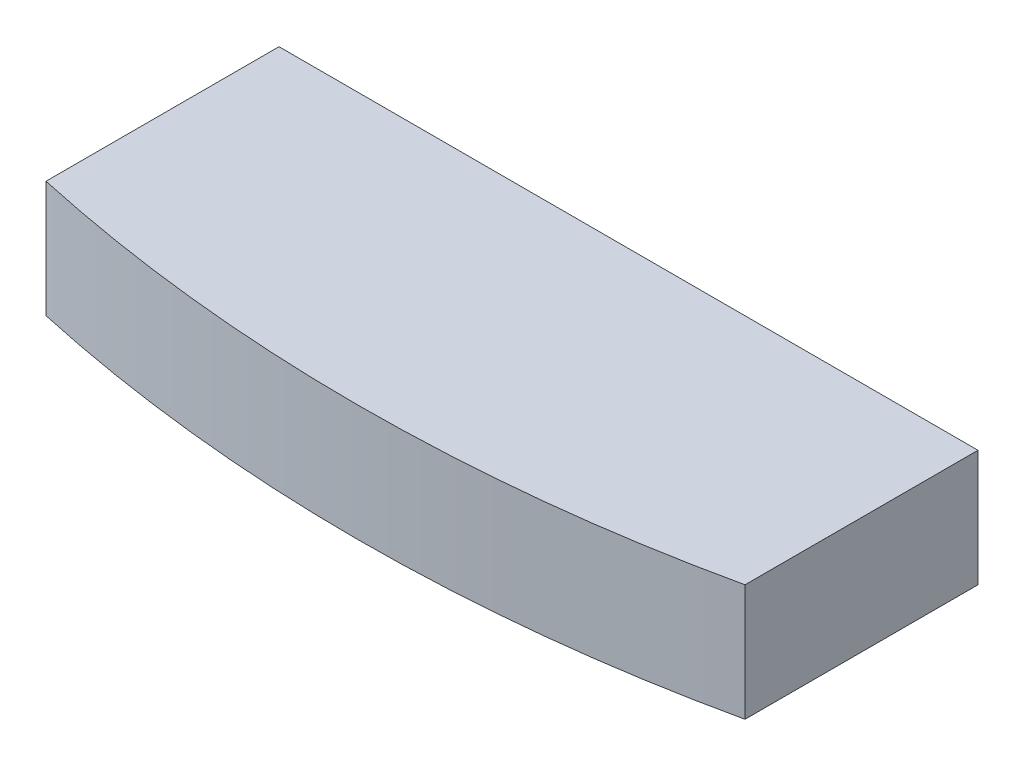
from build123d import *

# Parameters (mm, degrees)
BOSS_EXTRUDE1_DEPTH = 12.7


with BuildPart() as part:
    # Sketch1 → Boss-Extrude1 (new body)
    with BuildSketch(Plane(origin=(0, 0, 0), x_dir=(1, 0, 0), z_dir=(0, 1, 0))):
        with BuildLine():
            Line((-38.1, -173.409838579), (-38.1, -148.009838579))
            Line((-38.1, -148.009838579), (0, -148.009838579))
            Line((0, -148.009838579), (0, -177.546))
            ThreePointArc((0, -177.546), (-19.161927299, -176.508930817), (-38.1, -173.409838579))
        make_face()
    boss_extrude1 = extrude(amount=BOSS_EXTRUDE1_DEPTH)

    # Mirror1: Boss-Extrude1 across plane
    add(boss_extrude1.mirror(Plane(origin=(0, 12.7, 148.009838579), x_dir=(0, 0, 1), z_dir=(-1, 0, 0))))


solid = part.part
